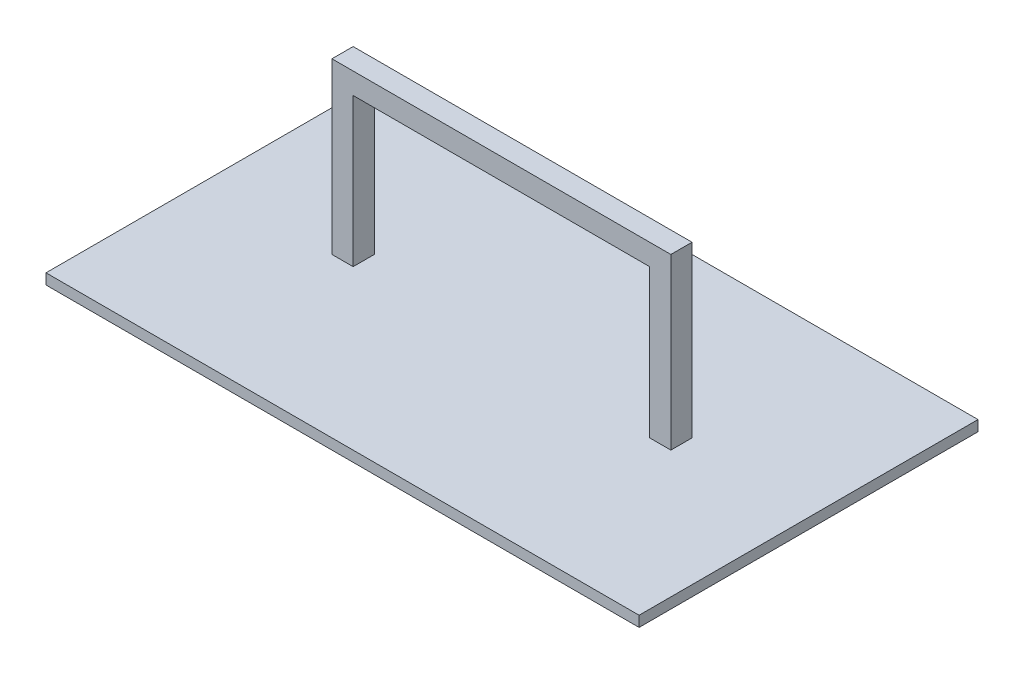
from build123d import *

# Parameters (mm, degrees)
SKETCH1_W           = 355.6
SKETCH1_H           = 203.2
BOSS_EXTRUDE1_DEPTH = 3.175
BOSS_EXTRUDE2_DEPTH = 6.35


with BuildPart() as part:
    # Sketch1 → Boss-Extrude1 (new body, symmetric)
    with BuildSketch(Plane(origin=(0, 0, 0), x_dir=(1, 0, 0), z_dir=(0, 1, 0))):
        Rectangle(SKETCH1_W, SKETCH1_H)
    extrude(amount=BOSS_EXTRUDE1_DEPTH, both=True)

    # Sketch2 → Boss-Extrude2 (add, symmetric)
    with BuildSketch(Plane.XY):
        Polygon((-101.6, 3.175), (-101.6, 104.775), (101.6, 104.775), (101.6, 3.175), (88.9, 3.175), (88.9, 92.075), (-88.9, 92.075), (-88.9, 3.175), align=None)
    extrude(amount=BOSS_EXTRUDE2_DEPTH, both=True)


solid = part.part
